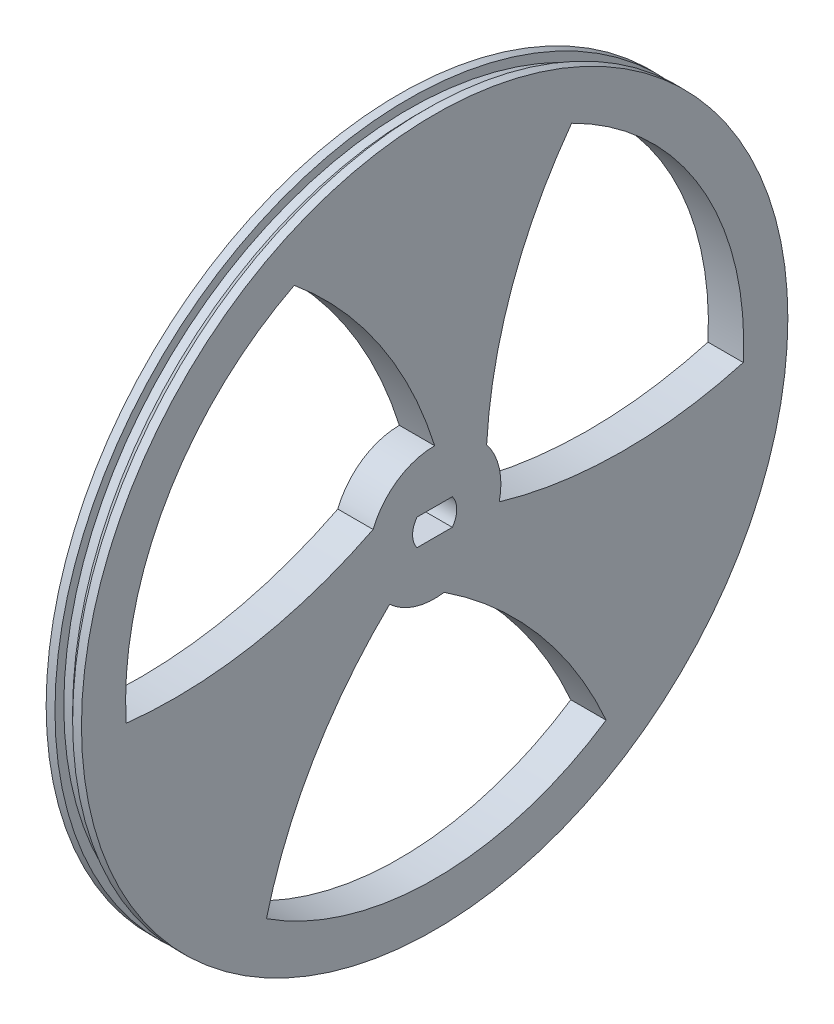
from build123d import *

# Parameters (mm, degrees)
SKETCH2_R           = 40
BOSS_EXTRUDE1_DEPTH = 4
SKETCH3_W           = 2
SKETCH3_H           = 1


with BuildPart() as part:
    # Sketch2 → Boss-Extrude1 (new body)
    with BuildSketch(Plane(origin=(0, 0, 0), x_dir=(0, 0, -1), z_dir=(1, 0, 0))):
        Circle(SKETCH2_R)
        with BuildLine():
            Line((-2, 1.5), (2, 1.5))
            ThreePointArc((2, 1.5), (2.5, 0), (2, -1.5))
            Line((2, -1.5), (-2, -1.5))
            ThreePointArc((-2, -1.5), (-2.5, 0), (-2, 1.5))
        make_face(mode=Mode.SUBTRACT)
        with BuildLine():
            ThreePointArc((-15.90290373, 31.178480607), (-30.419515024, 17.310491203), (-34.927407255, -2.253047362))
            ThreePointArc((-34.927407255, -2.253047362), (-20.583361548, -1.767102241), (-6.968299733, 2.77358952))
            ThreePointArc((-6.968299733, 2.77358952), (-4.209992791, 6.206928443), (0, 7.5))
            ThreePointArc((0, 7.5), (-6.227172355, 20.497298183), (-15.90290373, 31.178480607))
        make_face(mode=Mode.SUBTRACT)
        with BuildLine():
            ThreePointArc((5.886148851, 4.64792983), (8.761325342, 18.709265117), (15.512507376, 31.374545653))
            ThreePointArc((15.512507376, 31.374545653), (30.201082646, 17.68882718), (34.952808122, -1.81692168))
            ThreePointArc((34.952808122, -1.81692168), (21.122165812, -3.688321149), (7.313076649, -1.664004186))
            ThreePointArc((7.313076649, -1.664004186), (7.315395834, 1.653778642), (5.886148851, 4.64792983))
        make_face(mode=Mode.SUBTRACT)
        with BuildLine():
            ThreePointArc((1.082150882, -7.42151935), (11.822036206, -16.942162875), (19.414899879, -29.12149829))
            ThreePointArc((19.414899879, -29.12149829), (0.218432378, -34.999318383), (-19.049904392, -29.361558927))
            ThreePointArc((-19.049904392, -29.361558927), (-13.755262718, -16.448171602), (-5.097608221, -5.501308065))
            ThreePointArc((-5.097608221, -5.501308065), (-2.2254836, -7.162207952), (1.082150882, -7.42151935))
        make_face(mode=Mode.SUBTRACT)
    extrude(amount=BOSS_EXTRUDE1_DEPTH)

    # Sketch3 → Cut-Revolve1 (revolve, cut)
    with BuildSketch(Plane.XY):
        with Locations((2, 39.5)):
            Rectangle(SKETCH3_W, SKETCH3_H)
    revolve(axis=Axis((-1.599073018, 0, 0), (1, 0, 0)), mode=Mode.SUBTRACT)

    # Sketch4 → Revolve1 (revolve)
    with BuildSketch(Plane.XY):
        Polygon((3, 40), (2, 39), (3, 39), align=None)
    revolve(axis=Axis((0, 0, 0), (1, 0, 0)))


solid = part.part
